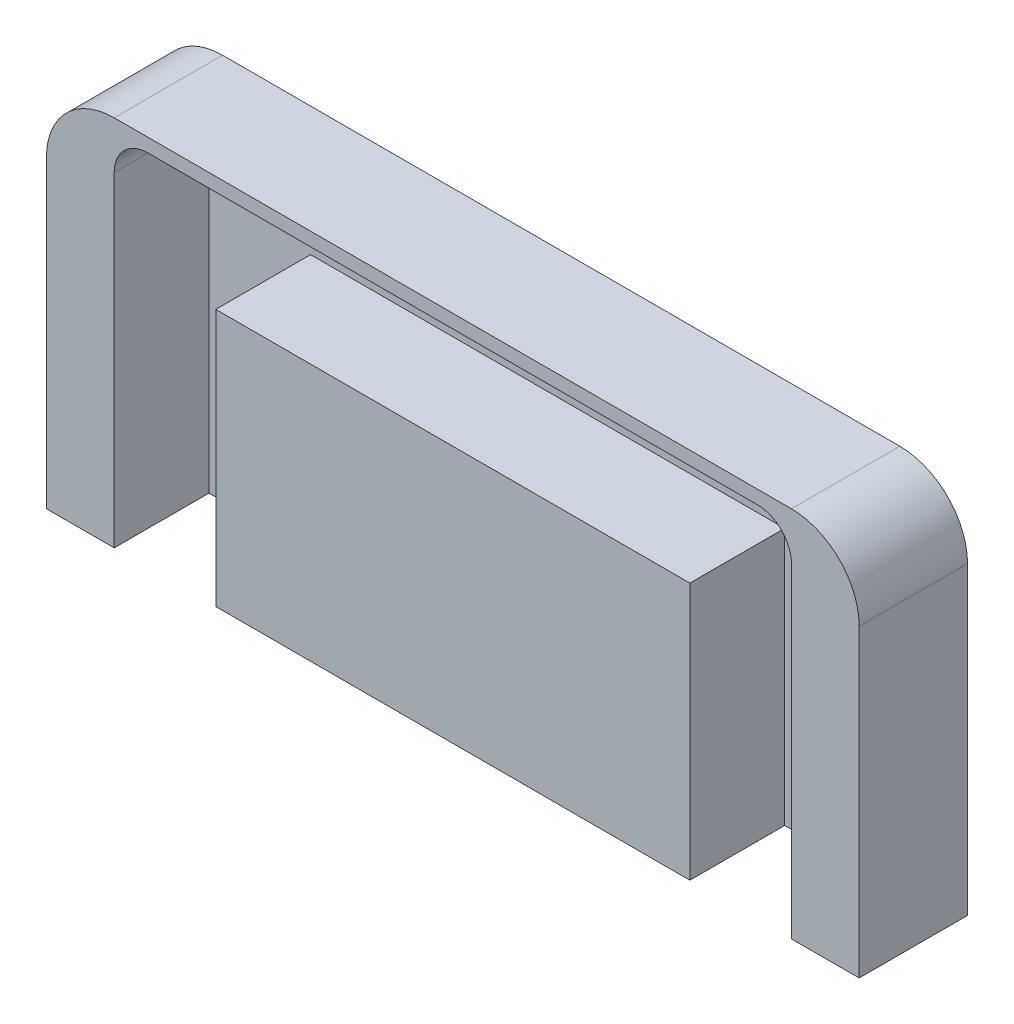
from build123d import *

# Parameters (mm, degrees)
SKETCH_1_W          = 24
SKETCH_1_H          = 11
EXTRUDE_1_DEPTH     = 3.2
SKETCH_2_W          = 20
SKETCH_2_H          = 3
CUT_EXTRUDE_1_DEPTH = 2.8
SKETCH_3_W          = 3
SKETCH_3_H          = 7.6
CUT_EXTRUDE_2_DEPTH = 2.8
FILLET_1_R          = 2
FILLET_2_R          = 1


with BuildPart() as part:
    # ｽｹｯﾁ1 → ﾎﾞｽ - 押し出し1 (new body)
    with BuildSketch(Plane.XY):
        with Locations((11.314402496, 5.5)):
            Rectangle(SKETCH_1_W, SKETCH_1_H)
    extrude(amount=EXTRUDE_1_DEPTH)

    # ｽｹｯﾁ2 → ｶｯﾄ - 押し出し1 (cut)
    with BuildSketch(Plane.XY.offset(3.2)):
        with Locations((11.314402496, 9.1)):
            Rectangle(SKETCH_2_W, SKETCH_2_H)
    extrude(amount=-CUT_EXTRUDE_1_DEPTH, mode=Mode.SUBTRACT)

    # ｽｹｯﾁ3 → ｶｯﾄ - 押し出し2 (cut)
    with BuildSketch(Plane.XY.offset(3.2)):
        with Locations((19.814402496, 3.8)):
            Rectangle(SKETCH_3_W, SKETCH_3_H)
        with Locations((2.814402496, 3.8)):
            Rectangle(SKETCH_3_W, SKETCH_3_H)
    extrude(amount=-CUT_EXTRUDE_2_DEPTH, mode=Mode.SUBTRACT)

    # ﾌｨﾚｯﾄ1
    fillet_1_edges = [part.edges().sort_by_distance(p)[0] for p in [
        (-0.685597504, 11, 1.6),
        (23.314402496, 11, 1.6),
    ]]
    fillet(fillet_1_edges, radius=FILLET_1_R)

    # ﾌｨﾚｯﾄ2
    fillet_2_edges = [part.edges().sort_by_distance(p)[0] for p in [
        (1.314402496, 10.6, 1.8),
        (21.314402496, 10.6, 1.8),
    ]]
    fillet(fillet_2_edges, radius=FILLET_2_R)


solid = part.part
